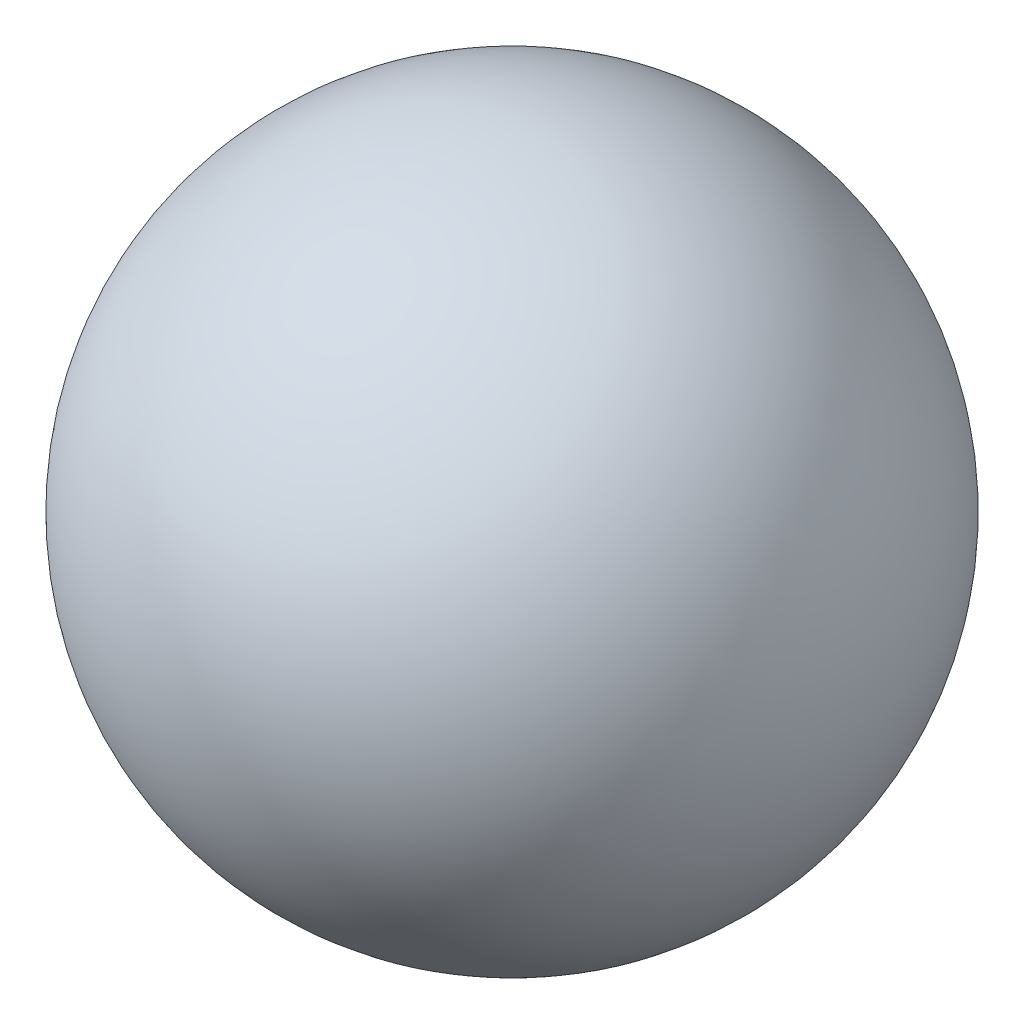
from build123d import *


with BuildPart() as part:
    # 草图1 → 旋转1 (revolve)
    with BuildSketch(Plane.XY):
        with BuildLine():
            Line((0, 8.5), (0, -8.5))
            ThreePointArc((0, -8.5), (8.5, 0), (0, 8.5))
        make_face()
    revolve(axis=Axis((0, 8.5, 0), (0, -1, 0)))


solid = part.part
